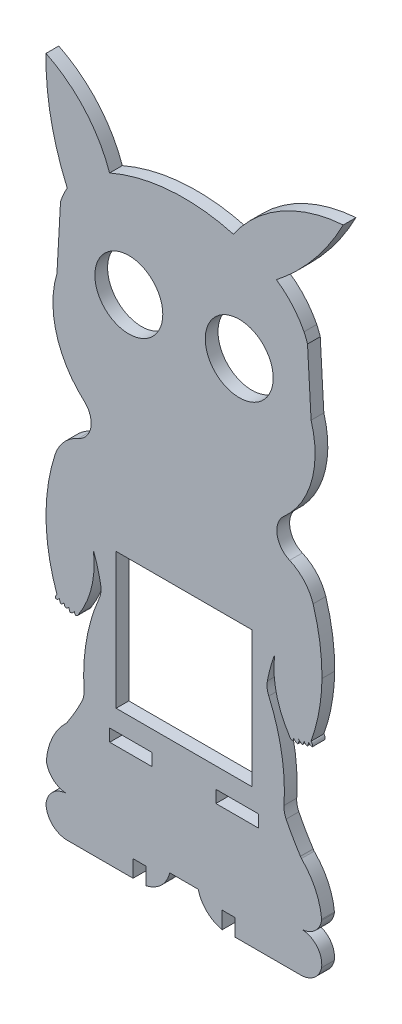
from build123d import *

# Parameters (mm, degrees)
MODEL_R                 = 8
MODEL_W                 = 10
MODEL_H                 = 2.9
SALIENTE_EXTRUIR1_DEPTH = 3


with BuildPart() as part:
    # Model → Saliente-Extruir1 (new body)
    with BuildSketch(Plane.XY):
        with BuildLine():
            Line((2.738139573, 79.958721833), (1.893307256, 64.837008948))
            ThreePointArc((1.893307256, 64.837008948), (1.804094173, 52.374094451), (8.490003457, 41.855976094))
            ThreePointArc((8.490003457, 41.855976094), (9.866643854, 37.389168926), (6.950289352, 33.736446451))
            ThreePointArc((6.950289352, 33.736446451), (3.525794094, 31.275549631), (1.420223138, 27.621818403))
            ThreePointArc((1.420223138, 27.621818403), (-0.672991735, 13.448943974), (1.903257207, -0.64413445))
            ThreePointArc((1.903257207, -0.64413445), (1.596863178, -1.105922047), (1.627780863, -1.659247614))
            ThreePointArc((1.627780863, -1.659247614), (2.122286511, -1.493378675), (2.468024937, -1.102849184))
            ThreePointArc((2.468024937, -1.102849184), (2.58077221, -1.616114359), (2.813255055, -2.087394334))
            ThreePointArc((2.813255055, -2.087394334), (3.27699089, -1.806143429), (3.602865379, -1.372601258))
            ThreePointArc((3.602865379, -1.372601258), (3.657014656, -1.871943312), (3.909736594, -2.306001204))
            ThreePointArc((3.909736594, -2.306001204), (4.43140284, -2.078027301), (4.811170789, -1.653899872))
            ThreePointArc((4.811170789, -1.653899872), (4.785196909, -2.222836522), (5.02214475, -2.740735426))
            ThreePointArc((5.02214475, -2.740735426), (5.596433055, -2.488050459), (6.0194762, -2.02470259))
            ThreePointArc((6.0194762, -2.02470259), (6.087237768, -2.398385139), (6.345526866, -2.676803923))
            ThreePointArc((6.345526866, -2.676803923), (6.76512344, -2.4701067), (7.016807649, -2.075847793))
            ThreePointArc((7.016807649, -2.075847793), (10.072385436, 5.017714023), (10.480834721, 12.730582753))
            ThreePointArc((10.480834721, 12.730582753), (11.467458305, 9.658521652), (12.192311398, 6.514388466))
            ThreePointArc((12.192311398, 6.514388466), (12.245025503, 5.0311028), (11.859988831, 3.59769361))
            ThreePointArc((11.859988831, 3.59769361), (8.838306655, -6.448503975), (8.27496016, -16.924156212))
            ThreePointArc((8.27496016, -16.924156212), (8.190311904, -18.223316893), (7.773132872, -19.456583068))
            ThreePointArc((7.773132872, -19.456583068), (6.18189197, -22.450615029), (4.403832579, -25.337616899))
            ThreePointArc((4.403832579, -25.337616899), (4.303591918, -25.529024451), (4.164576282, -25.69443211))
            ThreePointArc((4.164576282, -25.69443211), (0.867440919, -30.254572833), (-0.599469924, -35.687266233))
            ThreePointArc((-0.599469924, -35.687266233), (-0.601989014, -35.811902896), (-0.588981272, -35.935884517))
            ThreePointArc((-0.588981272, -35.935884517), (0.978789677, -38.80548638), (3.98481018, -40.092483401))
            ThreePointArc((3.98481018, -40.092483401), (0.856364533, -41.485661692), (-0.680047474, -44.546308039))
            ThreePointArc((-0.680047474, -44.546308039), (0.784377961, -48.081916287), (4.319952525, -49.54642304))
            Line((4.319952525, -49.54642304), (19.820067057, -49.54642304))
            Line((19.820067057, -49.54642304), (19.820067057, -45.54642304))
            Line((19.820067057, -45.54642304), (22.820067057, -45.54642304))
            Line((22.820067057, -45.54642304), (22.820067057, -49.54642304))
            ThreePointArc((22.820067057, -49.54642304), (26.431019228, -47.64752109), (28.47138138, -44.114572394))
            Line((28.47138138, -44.114572394), (35.168752734, -44.114572394))
            ThreePointArc((35.168752734, -44.114572394), (37.209114886, -47.64752109), (40.820067057, -49.54642304))
            Line((40.820067057, -49.54642304), (40.820067057, -45.54642304))
            Line((40.820067057, -45.54642304), (43.820067057, -45.54642304))
            Line((43.820067057, -45.54642304), (43.820067057, -49.54642304))
            Line((43.820067057, -49.54642304), (59.320181589, -49.54642304))
            ThreePointArc((59.320181589, -49.54642304), (62.461382403, -48.436520397), (64.208012382, -45.599566018))
            ThreePointArc((64.208012382, -45.599566018), (63.165796759, -41.825774349), (59.655323933, -40.092483401))
            ThreePointArc((59.655323933, -40.092483401), (62.661344437, -38.80548638), (64.229115385, -35.935884517))
            ThreePointArc((64.229115385, -35.935884517), (64.242123128, -35.811902896), (64.239604038, -35.687266233))
            ThreePointArc((64.239604038, -35.687266233), (62.731421175, -30.274249113), (59.475557832, -25.69443211))
            ThreePointArc((59.475557832, -25.69443211), (59.336542196, -25.529024451), (59.236301535, -25.337616899))
            ThreePointArc((59.236301535, -25.337616899), (57.458242143, -22.450615029), (55.867001242, -19.456583068))
            ThreePointArc((55.867001242, -19.456583068), (55.449822209, -18.223316893), (55.365173954, -16.924156212))
            ThreePointArc((55.365173954, -16.924156212), (54.801827459, -6.448503975), (51.780145282, 3.59769361))
            ThreePointArc((51.780145282, 3.59769361), (51.395108611, 5.0311028), (51.447822716, 6.514388466))
            ThreePointArc((51.447822716, 6.514388466), (52.172675809, 9.658521652), (53.159299392, 12.730582753))
            ThreePointArc((53.159299392, 12.730582753), (53.567748677, 5.017714023), (56.623326464, -2.075847793))
            ThreePointArc((56.623326464, -2.075847793), (56.875010673, -2.4701067), (57.294607248, -2.676803923))
            ThreePointArc((57.294607248, -2.676803923), (57.552896345, -2.398385139), (57.620657914, -2.02470259))
            ThreePointArc((57.620657914, -2.02470259), (58.043701059, -2.488050459), (58.617989364, -2.740735426))
            ThreePointArc((58.617989364, -2.740735426), (58.854937205, -2.222836522), (58.828963324, -1.653899872))
            ThreePointArc((58.828963324, -1.653899872), (59.208731274, -2.078027301), (59.73039752, -2.306001204))
            ThreePointArc((59.73039752, -2.306001204), (59.983119457, -1.871943312), (60.037268735, -1.372601258))
            ThreePointArc((60.037268735, -1.372601258), (60.363143224, -1.806143429), (60.826879059, -2.087394334))
            ThreePointArc((60.826879059, -2.087394334), (61.059361903, -1.616114359), (61.172109176, -1.102849184))
            ThreePointArc((61.172109176, -1.102849184), (61.517847602, -1.493378675), (62.012353251, -1.659247614))
            ThreePointArc((62.012353251, -1.659247614), (62.043270935, -1.105922047), (61.736876906, -0.64413445))
            ThreePointArc((61.736876906, -0.64413445), (63.602383612, 6.292702198), (64.312985392, 13.440769284))
            ThreePointArc((64.312985392, 13.440769284), (63.807919995, 20.611213234), (62.219910975, 27.621818403))
            ThreePointArc((62.219910975, 27.621818403), (60.11434002, 31.275549631), (56.689844761, 33.736446451))
            ThreePointArc((56.689844761, 33.736446451), (53.773490259, 37.389168926), (55.150130657, 41.855976094))
            ThreePointArc((55.150130657, 41.855976094), (61.836039941, 52.374094451), (61.746826857, 64.837008948))
            Line((61.746826857, 64.837008948), (60.901994541, 79.958721833))
            ThreePointArc((60.901994541, 79.958721833), (60.52523779, 81.01221194), (60.082132629, 82.039560406))
            ThreePointArc((60.082132629, 82.039560406), (57.301545651, 86.145115147), (53.573638816, 89.414664704))
            ThreePointArc((53.573638816, 89.414664704), (56.089558762, 91.529262633), (58.501636282, 93.761584207))
            ThreePointArc((58.501636282, 93.761584207), (64.487990723, 100.682191439), (69.3188096, 108.45357696))
            ThreePointArc((69.3188096, 108.45357696), (54.700807458, 103.978782371), (43.444082198, 93.634899654))
            ThreePointArc((43.444082198, 93.634899654), (28.686150355, 95.095319384), (14.288476391, 91.540553218))
            ThreePointArc((14.288476391, 91.540553218), (8.469304852, 101.471337422), (-0.6811904, 108.45357696))
            ThreePointArc((-0.6811904, 108.45357696), (0.464967816, 95.691689927), (4.311825224, 83.469532696))
            ThreePointArc((4.311825224, 83.469532696), (3.428504493, 81.757372515), (2.738139573, 79.958721833))
        make_face()
        with Locations((18.820067057, 68.975620222)):
            Circle(MODEL_R, mode=Mode.SUBTRACT)
        with Locations((44.820067057, 68.975620222)):
            Circle(MODEL_R, mode=Mode.SUBTRACT)
        with Locations((44.320067057, -23.09642304)):
            Rectangle(MODEL_W, MODEL_H, mode=Mode.SUBTRACT)
        with Locations((19.320067057, -23.09642304)):
            Rectangle(MODEL_W, MODEL_H, mode=Mode.SUBTRACT)
        Polygon((32.320067057, 15.131610977), (47.820067057, 15.131610977), (47.820067057, -16.868389023), (15.820067057, -16.868389023), (15.820067057, 15.131610977), align=None, mode=Mode.SUBTRACT)
    extrude(amount=SALIENTE_EXTRUIR1_DEPTH)


solid = part.part
